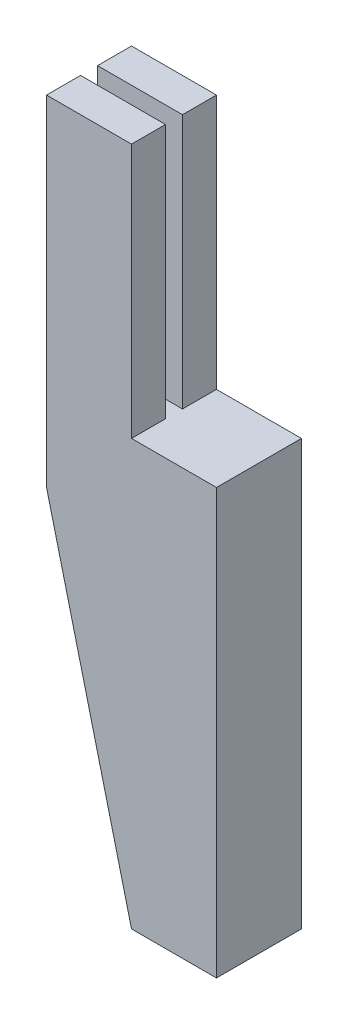
from build123d import *

# Parameters (mm, degrees)
BOSS_EXTRUDE1_DEPTH = 10
SKETCH2_W           = 10
SKETCH2_H           = 2
CUT_EXTRUDE1_DEPTH  = 30


with BuildPart() as part:
    # Sketch1 → Boss-Extrude1 (new body)
    with BuildSketch(Plane.XY):
        Polygon((0, 0), (0, 30), (-10, 30), (-10, -10), (0, -50), (10, -50), (10, 0), align=None)
    extrude(amount=BOSS_EXTRUDE1_DEPTH)

    # Sketch2 → Cut-Extrude1 (cut)
    with BuildSketch(Plane(origin=(0, 30, 0), x_dir=(1, 0, 0), z_dir=(0, 1, 0))):
        with Locations((-5, -5)):
            Rectangle(SKETCH2_W, SKETCH2_H)
    extrude(amount=-CUT_EXTRUDE1_DEPTH, mode=Mode.SUBTRACT)


solid = part.part
